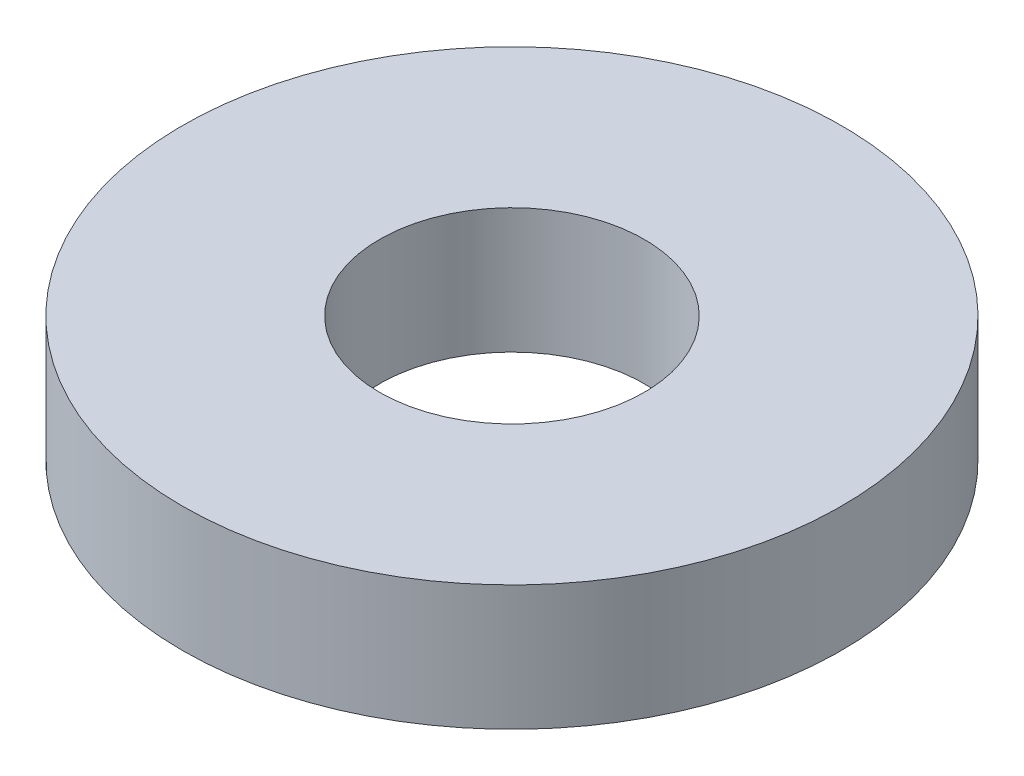
from build123d import *

# Parameters (mm, degrees)
SKETCH1_R      = 7.8994
SKETCH1_R_2    = 3.175
EXTRUDE1_DEPTH = 2.9972


with BuildPart() as part:
    # Sketch1 → Extrude1 (new body)
    with BuildSketch(Plane(origin=(0, 0, 0), x_dir=(1, 0, 0), z_dir=(0, 1, 0))):
        with Locations((-5.912279496, 13.86327606)):
            Circle(SKETCH1_R)
        with Locations((-5.912279496, 13.86327606)):
            Circle(SKETCH1_R_2, mode=Mode.SUBTRACT)
    extrude(amount=EXTRUDE1_DEPTH)


solid = part.part
